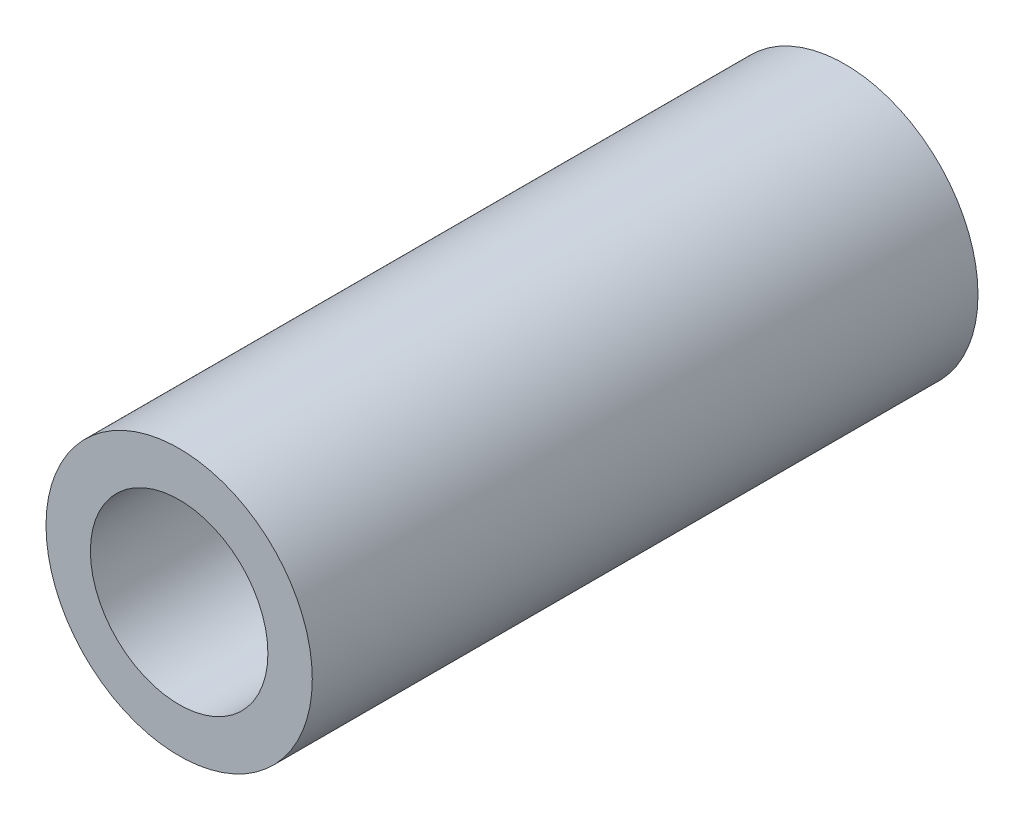
from build123d import *

# Parameters (mm, degrees)
SKETCH1_R           = 7.62
SKETCH1_R_2         = 5.08
BOSS_EXTRUDE1_DEPTH = 38.1


with BuildPart() as part:
    # Sketch1 → Boss-Extrude1 (new body)
    with BuildSketch(Plane.XY):
        Circle(SKETCH1_R)
        Circle(SKETCH1_R_2, mode=Mode.SUBTRACT)
    extrude(amount=BOSS_EXTRUDE1_DEPTH)


solid = part.part
